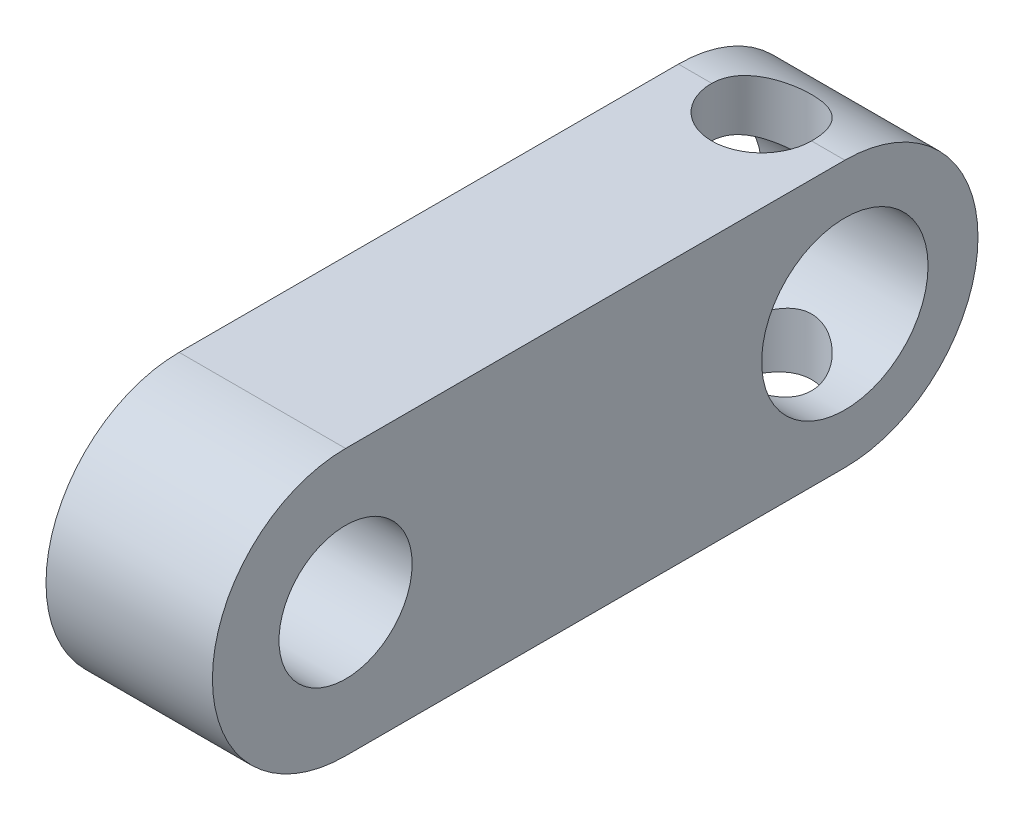
from build123d import *

# Parameters (mm, degrees)
SKETCH_1_R          = 4
SKETCH_1_R_2        = 5
EXTRUDE_1_DEPTH     = 10
SKETCH_2_R          = 3
CUT_EXTRUDE_1_DEPTH = 17


with BuildPart() as part:
    # 草图1 → 凸台-拉伸1 (new body)
    with BuildSketch(Plane(origin=(0, 0, 0), x_dir=(0, 0, -1), z_dir=(1, 0, 0))):
        with BuildLine():
            Line((15, 8), (-15, 8))
            ThreePointArc((-15, 8), (-23, 0), (-15, -8))
            Line((-15, -8), (15, -8))
            ThreePointArc((15, -8), (23, 0), (15, 8))
        make_face()
        with Locations((-15, 0)):
            Circle(SKETCH_1_R, mode=Mode.SUBTRACT)
        with Locations((15, 0)):
            Circle(SKETCH_1_R_2, mode=Mode.SUBTRACT)
    extrude(amount=EXTRUDE_1_DEPTH)

    # 草图2 → 切除-拉伸1 (cut, through all)
    with BuildSketch(Plane(origin=(0, 8, 0), x_dir=(1, 0, 0), z_dir=(0, 1, 0))):
        with Locations((5, 15)):
            Circle(SKETCH_2_R)
    extrude(amount=-CUT_EXTRUDE_1_DEPTH, mode=Mode.SUBTRACT)


solid = part.part
